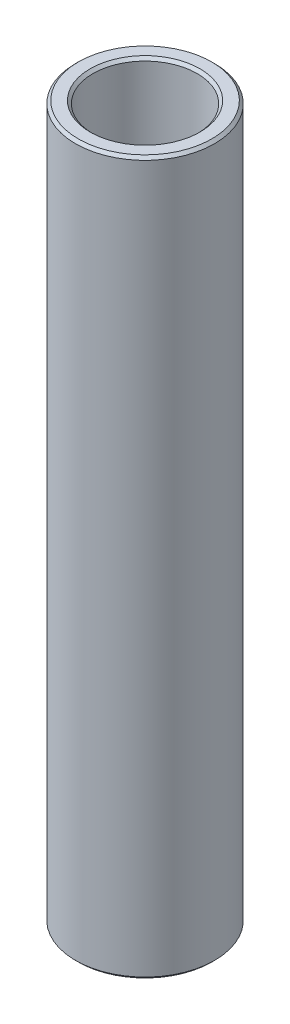
from build123d import *

# Parameters (mm, degrees)
SKETCH1_W     = 1.5875
SKETCH1_H     = 65.135434212
CHAMFER1_SIZE = 0.254


with BuildPart() as part:
    # Sketch1 → Revolve1 (revolve)
    with BuildSketch(Plane.XY):
        with Locations((5.55625, 95.866570161)):
            Rectangle(SKETCH1_W, SKETCH1_H)
    revolve(axis=Axis((0, 53.773853055, 0), (0, 1, 0)))

    # Chamfer1
    chamfer1_edges = [part.edges().sort_by_distance(p)[0] for p in [
        (-6.35, 63.298853055, 0),
        (-6.35, 128.434287267, 0),
        (-4.7625, 128.434287267, 0),
        (-4.7625, 63.298853055, 0),
    ]]
    chamfer(chamfer1_edges, length=CHAMFER1_SIZE)


solid = part.part
